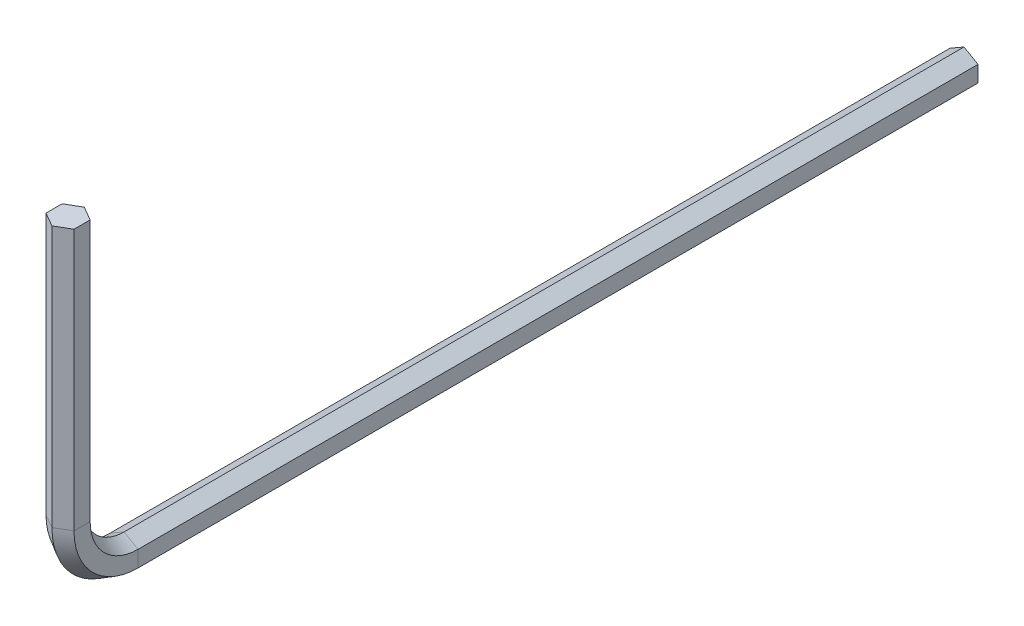
from build123d import *


with BuildPart() as part:
    # Sweep1: sweep along a curve in space
    with BuildLine() as sweep1_path:
        Line((0, 0, 0), (0, 0, 45))
        ThreePointArc((0, 3, 48), (0, 0.878679656, 47.121320344), (0, 0, 45))
        Line((0, 3, 48), (0, 17, 48))
    # Sketch1 → Sweep1 (sweep)
    with BuildSketch(Plane(origin=(0, 0, 0), x_dir=(0, 1, 0), z_dir=(0, 0, 1))):
        Polygon((0.866025404, 0), (0.433012702, 0.75), (-0.433012702, 0.75), (-0.866025404, 0), (-0.433012702, -0.75), (0.433012702, -0.75), align=None)
    sweep(path=sweep1_path.line)


solid = part.part
